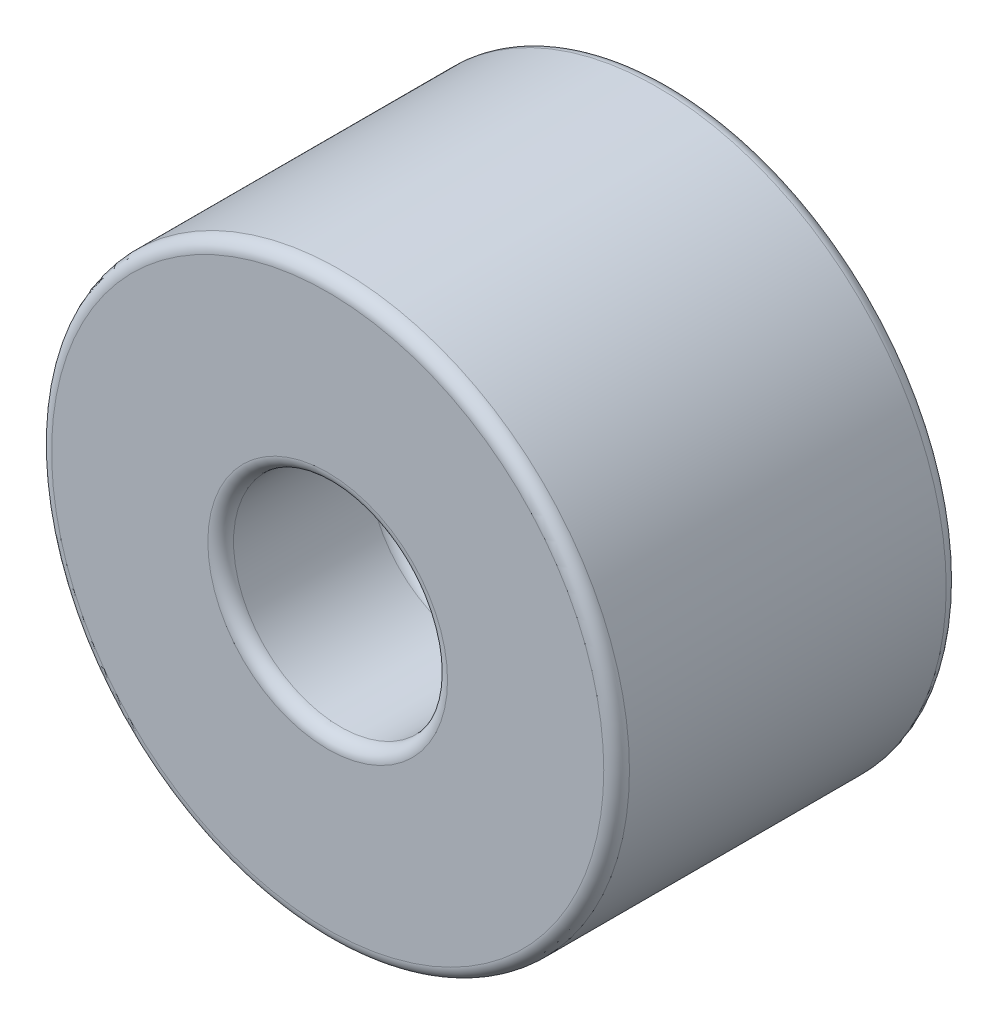
from build123d import *

# Parameters (mm, degrees)
SKETCH1_R           = 135
BOSS_EXTRUDE2_DEPTH = 160
SKETCH3_R           = 50
CUT_EXTRUDE1_DEPTH  = 75
SKETCH4_R           = 50
CUT_EXTRUDE2_DEPTH  = 75
FILLET1_R           = 6
SKETCH5_R           = 4
CUT_EXTRUDE3_DEPTH  = 45
SKETCH6_R           = 6.5
CUT_EXTRUDE4_DEPTH  = 86


with BuildPart() as part:
    # Sketch1 → Boss-Extrude2 (new body)
    with BuildSketch(Plane.XY):
        Circle(SKETCH1_R)
    extrude(amount=BOSS_EXTRUDE2_DEPTH)

    # Sketch3 → Cut-Extrude1 (cut)
    with BuildSketch(Plane.XY.offset(160)):
        Circle(SKETCH3_R)
    extrude(amount=-CUT_EXTRUDE1_DEPTH, mode=Mode.SUBTRACT)

    # Sketch4 → Cut-Extrude2 (cut)
    with BuildSketch(Plane(origin=(0, 0, 0), x_dir=(-1, 0, 0), z_dir=(0, 0, -1))):
        Circle(SKETCH4_R)
    extrude(amount=-CUT_EXTRUDE2_DEPTH, mode=Mode.SUBTRACT)

    # Fillet1
    fillet1_edges = [part.edges().sort_by_distance(p)[0] for p in [
        (50, 0, 75),
        (50, 0, 0),
        (-135, 0, 0),
        (-135, 0, 160),
        (-50, 0, 85),
        (-50, 0, 160),
    ]]
    fillet(fillet1_edges, radius=FILLET1_R)

    # Sketch5 → Cut-Extrude3 (cut)
    with BuildSketch(Plane.XY.offset(85)):
        with Locations((35, 0)):
            Circle(SKETCH5_R)
        with Locations((-17.5, -30.310889132)):
            Circle(SKETCH5_R)
        with Locations((-17.5, 30.310889132)):
            Circle(SKETCH5_R)
    extrude(amount=-CUT_EXTRUDE3_DEPTH, mode=Mode.SUBTRACT)

    # Sketch6 → Cut-Extrude4 (cut, through all)
    with BuildSketch(Plane.XY.offset(85)):
        Circle(SKETCH6_R)
    extrude(amount=-CUT_EXTRUDE4_DEPTH, mode=Mode.SUBTRACT)


solid = part.part
